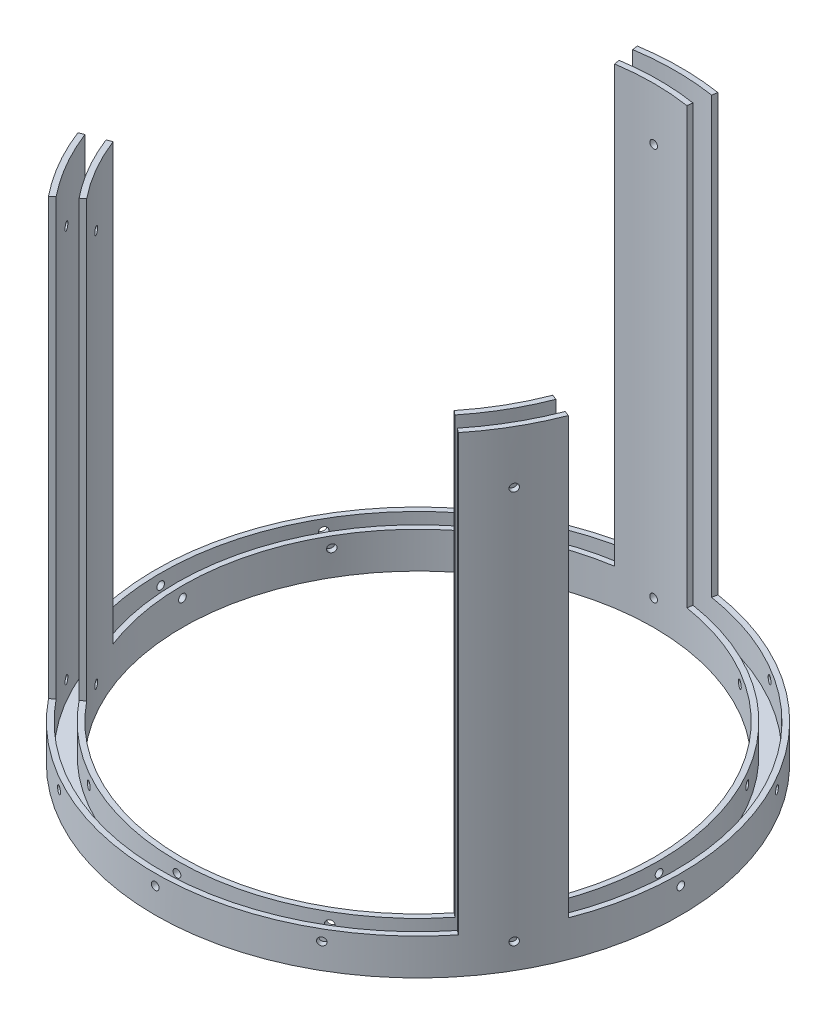
from build123d import *
from build123d.topology import SkipClean

# Parameters (mm, degrees)
SKETCH1_R                      = 92.075
SKETCH1_R_2                    = 82.55
BOSS_EXTRUDE1_DEPTH            = 12.7
CUT_EXTRUDE2_REACH             = 132.832
CUT_EXTRUDE2_END_RADIUS        = 92.075
SKETCH3_R                      = 1.35255
CIRPATTERN1_COUNT              = 12
BOSS_EXTRUDE2_DEPTH            = 152.4
LPATTERN1_COUNT                = 2
LPATTERN1_PITCH                = 137.668
CIRPATTERN2_COUNT              = 3
CIRPATTERN2_COPY_1_REACH       = 132.832
CIRPATTERN2_COPY_1_END_RADIUS  = 92.075
CIRPATTERN2_COPY_1_SKETCH_R    = 1.35255
CIRPATTERN2_COPY_2_REACH       = 132.832
CIRPATTERN2_COPY_2_END_RADIUS  = 92.075
CIRPATTERN2_COPY_2_SKETCH_R    = 1.35255
CIRPATTERN2_COPY_3_REACH       = 132.832
CIRPATTERN2_COPY_3_END_RADIUS  = 92.075
CIRPATTERN2_COPY_3_SKETCH_R    = 1.35255
CIRPATTERN2_COPY_4_REACH       = 132.832
CIRPATTERN2_COPY_4_END_RADIUS  = 92.075
CIRPATTERN2_COPY_4_SKETCH_R    = 1.35255
SKETCH2_R                      = 90.17
SKETCH2_R_2                    = 84.455
CUT_EXTRUDE1_DEPTH             = 10.16
CUT_EXTRUDE1_DIRECTION_2_REACH = 202.453


with BuildPart() as part:
    # Sketch1 → Boss-Extrude1 (new body)
    with BuildSketch(Plane(origin=(0, 0, 0), x_dir=(1, 0, 0), z_dir=(0, 1, 0))):
        with Locations(Location((0, 0, 0), (0, 0, 270))):
            Circle(SKETCH1_R)
        with Locations(Location((0, 0, 0), (0, 0, 270))):
            Circle(SKETCH1_R_2, mode=Mode.SUBTRACT)
    extrude(amount=BOSS_EXTRUDE1_DEPTH)

    # Cut-Extrude2: up to this cylinder (the profile starts inside it)
    cut_extrude2_end = Plane(origin=(0, 8.89, 0), z_dir=(0, -1, 0)) * Cylinder(CUT_EXTRUDE2_END_RADIUS, 450.814, mode=Mode.PRIVATE)
    # Sketch3 → Cut-Extrude2 (cut, up to the surface)
    with BuildSketch(Plane.XY, mode=Mode.PRIVATE) as cut_extrude2_sk1:
        with Locations((0, 8.89)):
            Circle(SKETCH3_R)
    cut_extrude2_tool1 = extrude(cut_extrude2_sk1.sketch, amount=-CUT_EXTRUDE2_REACH, mode=Mode.PRIVATE) & cut_extrude2_end
    cut_extrude2 = cut_extrude2_tool1.solids().sort_by_distance((0, 8.89, 0))[0]
    add(cut_extrude2, mode=Mode.SUBTRACT)

    # CirPattern1: Cut-Extrude2 ×12 about axis
    cirpattern1_axis = Axis((0, 12.7, 0), (0, 1, 0))
    for i in range(1, CIRPATTERN1_COUNT):
        add(cut_extrude2.rotate(cirpattern1_axis, i * 360 / CIRPATTERN1_COUNT), mode=Mode.SUBTRACT)

    # Sketch4 → Boss-Extrude2 (add)
    with SkipClean():  # the faces are left unmerged after this step: merging them gives an invalid solid
        with BuildSketch(Plane(origin=(0, 12.7, 0), x_dir=(1, 0, 0), z_dir=(0, 1, 0))):
            with BuildLine():
                Line((-12.7, 81.567226875), (-14.165384615, 90.978829975))
                ThreePointArc((-14.165384615, 90.978829975), (-0.056482912, 92.074982675), (14.053753031, 90.996140856))
                Line((14.053753031, 90.996140856), (12.599916511, 81.582746975))
                ThreePointArc((12.599916511, 81.582746975), (-0.050639852, 82.549984468), (-12.7, 81.567226875))
            make_face()
        boss_extrude2 = extrude(amount=BOSS_EXTRUDE2_DEPTH)

    # LPattern1: Cut-Extrude2 ×2
    with SkipClean():  # the faces are left unmerged after this step: merging them gives an invalid solid
        with Locations(*[(0, i * LPATTERN1_PITCH, 0) for i in range(1, LPATTERN1_COUNT)]):
            add(cut_extrude2, mode=Mode.SUBTRACT)

    # CirPattern2: Boss-Extrude2 ×3 about axis
    with SkipClean():  # the faces are left unmerged after this step: merging them gives an invalid solid
        cirpattern2_axis = Axis((0, 0, 0), (0, 1, 0))
        for i in range(1, CIRPATTERN2_COUNT):
            add(boss_extrude2.rotate(cirpattern2_axis, i * 360 / CIRPATTERN2_COUNT))

    # CirPattern2 copy 1: up to this cylinder (the profile starts inside it)
    with SkipClean():  # the faces are left unmerged after this step: merging them gives an invalid solid
        cirpattern2_copy_1_end = Plane(origin=(0, 8.89, 0), z_dir=(0, -1, 0)) * Cylinder(CIRPATTERN2_COPY_1_END_RADIUS, 450.814, mode=Mode.PRIVATE)
        # CirPattern2 copy 1 sketch → CirPattern2 copy 1 (cut, up to the surface)
        with BuildSketch(Plane(origin=(0, 137.668, 0), x_dir=(-0.4999999999999998, 0, -0.8660254037844387), z_dir=(0.8660254037844387, 0, -0.4999999999999998)), mode=Mode.PRIVATE) as cirpattern2_copy_1_sk1:
            with Locations((0, 8.89)):
                Circle(CIRPATTERN2_COPY_1_SKETCH_R)
        cirpattern2_copy_1_tool1 = extrude(cirpattern2_copy_1_sk1.sketch, amount=-CIRPATTERN2_COPY_1_REACH, mode=Mode.PRIVATE) & cirpattern2_copy_1_end
        add(cirpattern2_copy_1_tool1.solids().sort_by_distance((0, 8.89, 0))[0], mode=Mode.SUBTRACT)

    # CirPattern2 copy 2: up to this cylinder (the profile starts inside it)
    with SkipClean():  # the faces are left unmerged after this step: merging them gives an invalid solid
        cirpattern2_copy_2_end = Plane(origin=(0, 8.89, 0), z_dir=(0, -1, 0)) * Cylinder(CIRPATTERN2_COPY_2_END_RADIUS, 450.814, mode=Mode.PRIVATE)
        # CirPattern2 copy 2 sketch → CirPattern2 copy 2 (cut, up to the surface)
        with BuildSketch(Plane(origin=(0, 137.668, 0), x_dir=(-0.5000000000000004, 0, 0.8660254037844384), z_dir=(-0.8660254037844384, 0, -0.5000000000000004)), mode=Mode.PRIVATE) as cirpattern2_copy_2_sk1:
            with Locations((0, 8.89)):
                Circle(CIRPATTERN2_COPY_2_SKETCH_R)
        cirpattern2_copy_2_tool1 = extrude(cirpattern2_copy_2_sk1.sketch, amount=-CIRPATTERN2_COPY_2_REACH, mode=Mode.PRIVATE) & cirpattern2_copy_2_end
        add(cirpattern2_copy_2_tool1.solids().sort_by_distance((0, 8.89, 0))[0], mode=Mode.SUBTRACT)

    # CirPattern2 copy 3: up to this cylinder (the profile starts inside it)
    with SkipClean():  # the faces are left unmerged after this step: merging them gives an invalid solid
        cirpattern2_copy_3_end = Plane(origin=(0, 8.89, 0), z_dir=(0, -1, 0)) * Cylinder(CIRPATTERN2_COPY_3_END_RADIUS, 450.814, mode=Mode.PRIVATE)
        # CirPattern2 copy 3 sketch → CirPattern2 copy 3 (cut, up to the surface)
        with BuildSketch(Plane(origin=(0, 0, 0), x_dir=(-0.4999999999999998, 0, -0.8660254037844387), z_dir=(0.8660254037844387, 0, -0.4999999999999998)), mode=Mode.PRIVATE) as cirpattern2_copy_3_sk1:
            with Locations((0, 8.89)):
                Circle(CIRPATTERN2_COPY_3_SKETCH_R)
        cirpattern2_copy_3_tool1 = extrude(cirpattern2_copy_3_sk1.sketch, amount=-CIRPATTERN2_COPY_3_REACH, mode=Mode.PRIVATE) & cirpattern2_copy_3_end
        add(cirpattern2_copy_3_tool1.solids().sort_by_distance((0, 8.89, 0))[0], mode=Mode.SUBTRACT)

    # CirPattern2 copy 4: up to this cylinder (the profile starts inside it)
    with SkipClean():  # the faces are left unmerged after this step: merging them gives an invalid solid
        cirpattern2_copy_4_end = Plane(origin=(0, 8.89, 0), z_dir=(0, -1, 0)) * Cylinder(CIRPATTERN2_COPY_4_END_RADIUS, 450.814, mode=Mode.PRIVATE)
        # CirPattern2 copy 4 sketch → CirPattern2 copy 4 (cut, up to the surface)
        with BuildSketch(Plane(origin=(0, 0, 0), x_dir=(-0.5000000000000004, 0, 0.8660254037844384), z_dir=(-0.8660254037844384, 0, -0.5000000000000004)), mode=Mode.PRIVATE) as cirpattern2_copy_4_sk1:
            with Locations((0, 8.89)):
                Circle(CIRPATTERN2_COPY_4_SKETCH_R)
        cirpattern2_copy_4_tool1 = extrude(cirpattern2_copy_4_sk1.sketch, amount=-CIRPATTERN2_COPY_4_REACH, mode=Mode.PRIVATE) & cirpattern2_copy_4_end
        add(cirpattern2_copy_4_tool1.solids().sort_by_distance((0, 8.89, 0))[0], mode=Mode.SUBTRACT)

    # Sketch2 → Cut-Extrude1 (cut)
    with SkipClean():  # the faces are left unmerged after this step: merging them gives an invalid solid
        with BuildSketch(Plane(origin=(0, 12.7, 0), x_dir=(1, 0, 0), z_dir=(0, 1, 0))):
            with Locations(Location((0, 0, 0), (0, 0, 81.220412479))):
                Circle(SKETCH2_R)
            with Locations(Location((0, 0, 0), (0, 0, 81.220412479))):
                Circle(SKETCH2_R_2, mode=Mode.SUBTRACT)
        extrude(amount=-CUT_EXTRUDE1_DEPTH, mode=Mode.SUBTRACT)

    # Cut-Extrude1 direction 2: up to this face of the body (flat: up to its plane)
    cut_extrude1_direction_2_end = Plane(part.part.faces().sort_by_distance((-0.053403253, 165.1, -87.054712721))[0])
    # Sketch2 → Cut-Extrude1 direction 2 (cut, up to the picked face)
    with BuildSketch(Plane(origin=(0, 12.7, 0), x_dir=(1, 0, 0), z_dir=(0, 1, 0)), mode=Mode.PRIVATE) as cut_extrude1_direction_2_sk1:
        with Locations(Location((0, 0, 0), (0, 0, 81.220412479))):
            Circle(SKETCH2_R)
        with Locations(Location((0, 0, 0), (0, 0, 81.220412479))):
            Circle(SKETCH2_R_2, mode=Mode.SUBTRACT)
    cut_extrude1_direction_2_tool1 = split(extrude(cut_extrude1_direction_2_sk1.sketch, amount=CUT_EXTRUDE1_DIRECTION_2_REACH, mode=Mode.PRIVATE), bisect_by=cut_extrude1_direction_2_end, keep=Keep.BOTH, mode=Mode.PRIVATE)
    add(cut_extrude1_direction_2_tool1.solids().sort_by(Axis((-13.37371, 12.7, 86.592953), (0, 1, 0)))[0], mode=Mode.SUBTRACT)


solid = part.part
